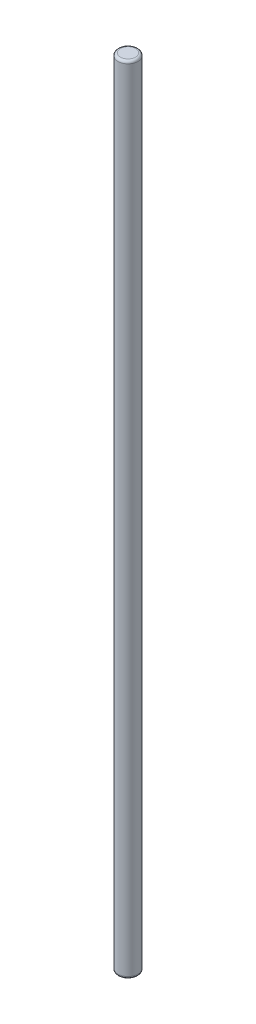
from build123d import *

# Parameters (mm, degrees)
SKETCH1_R           = 4
BOSS_EXTRUDE1_DEPTH = 317
FILLET2_R           = 1


with BuildPart() as part:
    # Sketch1 → Boss-Extrude1 (new body)
    with BuildSketch(Plane(origin=(0, 0, 0), x_dir=(1, 0, 0), z_dir=(0, 1, 0))):
        Circle(SKETCH1_R)
    extrude(amount=BOSS_EXTRUDE1_DEPTH)

    # Fillet2
    fillet2_edges = [part.edges().sort_by_distance(p)[0] for p in [
        (-4, 0, 0),
        (-4, 317, 0),
    ]]
    fillet(fillet2_edges, radius=FILLET2_R)


solid = part.part
